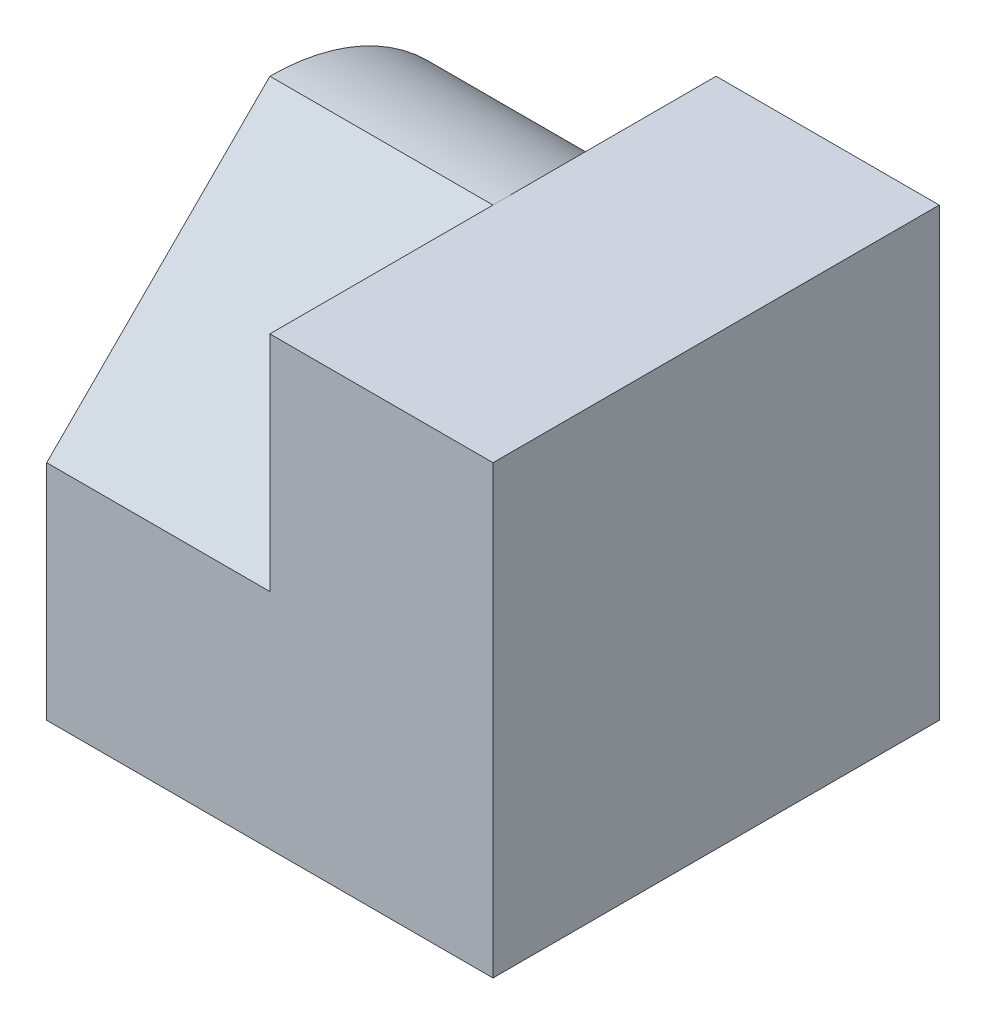
from build123d import *

# Parameters (mm, degrees)
SKETCH1_W           = 4
SKETCH1_H           = 4
BOSS_EXTRUDE1_DEPTH = 4
CUT_EXTRUDE1_DEPTH  = 2


with BuildPart() as part:
    # Sketch1 → Boss-Extrude1 (new body)
    with BuildSketch(Plane(origin=(0, 0, 0), x_dir=(1, 0, 0), z_dir=(0, 1, 0))):
        Rectangle(SKETCH1_W, SKETCH1_H)
    extrude(amount=BOSS_EXTRUDE1_DEPTH)

    # Sketch2 → Cut-Extrude1 (cut)
    with BuildSketch(Plane.ZY.offset(2)):
        Polygon((0, 4), (2, 2), (2, 4), align=None)
        with BuildLine():
            ThreePointArc((-2, 2), (-1.414213562, 3.414213562), (0, 4))
            Line((0, 4), (-2, 4))
            Line((-2, 4), (-2, 2))
        make_face()
    extrude(amount=-CUT_EXTRUDE1_DEPTH, mode=Mode.SUBTRACT)


solid = part.part
